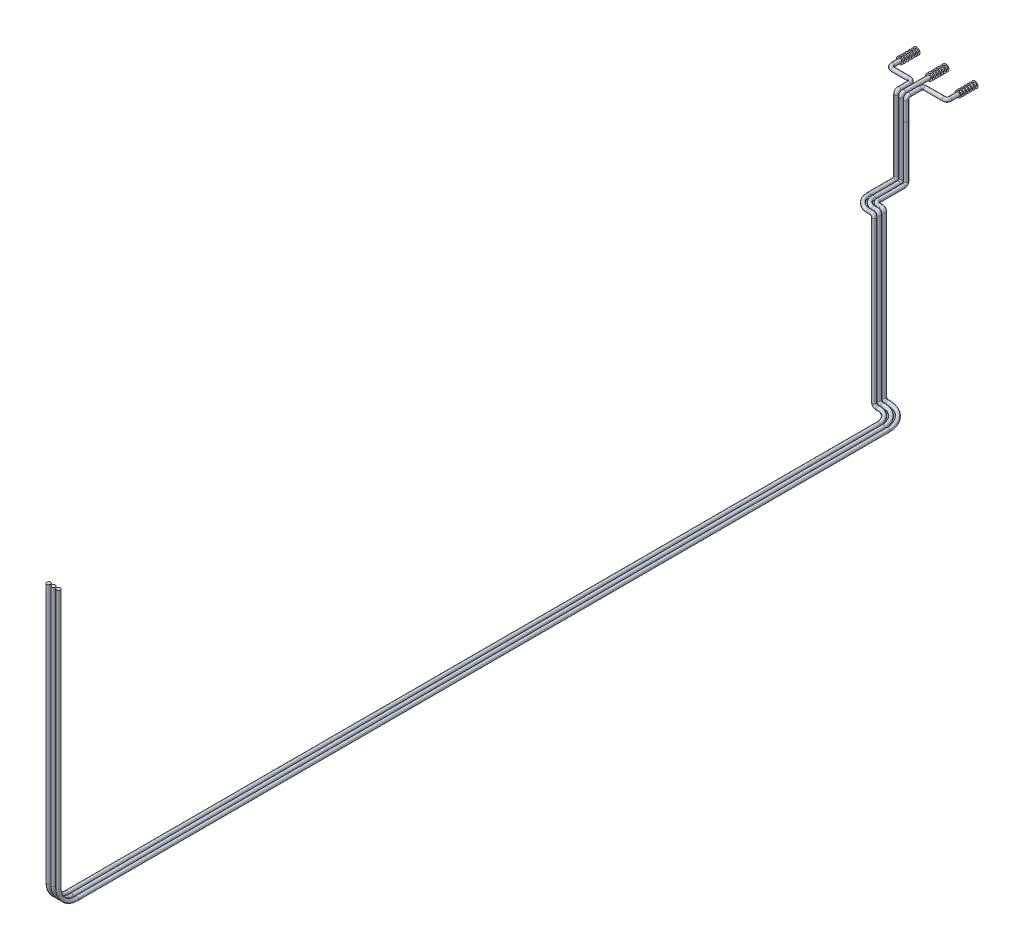
from build123d import *

# Parameters (mm, degrees)
BARRER5_PROFILE_R       = 13.7
BARRER6_PROFILE_R       = 13.7
CROQUIS41_R             = 13.7
CROQUIS62_R             = 22.870183784
CROQUIS62_R_2           = 24.36570856
CROQUIS62_R_3           = 24.738020287
SALIENTE_EXTRUIR1_DEPTH = 1
MATRIZL1_COUNT          = 7
MATRIZL1_PITCH          = 20
CROQUIS64_W             = 239.066100256
CROQUIS64_H             = 33.201144274
CORTAR_EXTRUIR1_DEPTH   = 5
CROQUIS65_R             = 13.7
CROQUIS65_R_2           = 13.697033


with BuildPart() as part:
    # Barrer5: sweep along a curve in space
    with BuildLine() as barrer5_path:
        Line((0, 0, 0), (0, 0, 170))
        ThreePointArc((0, 0, 170), (8.786796564, 0, 191.213203436), (30, 0, 200))
        Line((30, 0, 200), (145.00018, 0, 200))
        ThreePointArc((145.00018, 0, 200), (166.213383436, 0, 208.786796564), (175.00018, 0, 230))
        Line((175.00018, 0, 230), (175.00018, 0, 300))
        ThreePointArc((175.00018, 0, 300), (175.00018, -5.857864376, 314.142135624), (175.00018, -20, 320))
        Line((175.00018, -20, 320), (175.00018, -156.800061359, 320))
    # Barrer5 profile (on start of the path) → Barrer5 (sweep)
    with BuildSketch(Plane.XY):
        Circle(BARRER5_PROFILE_R)
    sweep(path=barrer5_path.line)


with BuildPart() as body_2:
    # Barrer6: sweep along a curve in space
    with BuildLine() as barrer6_path:
        Line((210, 0, 0), (210, 0, 299.997033))
        ThreePointArc((210, 0, 299.997033), (210, -5.857864376, 314.139168624), (210, -20, 319.997033))
        Line((210, -20, 319.997033), (210, -153.425324093, 319.997033))
    # Barrer6 profile (on start of the path) → Barrer6 (sweep)
    with BuildSketch(Plane(origin=(210, 0, 0), x_dir=(1, 0, 0), z_dir=(0, 0, 1))):
        Circle(BARRER6_PROFILE_R)
    sweep(path=barrer6_path.line)


with BuildPart() as body_3:
    # Barrer7: sweep along a curve in space
    with BuildLine() as barrer7_path:
        Line((420, 0, 0), (420, 0, 180))
        ThreePointArc((420, 0, 180), (414.142135624, 0, 194.142135624), (400, 0, 200))
        Line((400, 0, 200), (264.998005, 0, 200))
        ThreePointArc((264.998005, 0, 200), (250.855869376, 0, 205.857864376), (244.998005, 0, 220))
        Line((244.998005, 0, 220), (244.998005, 0, 300))
        ThreePointArc((244.998005, 0, 300), (244.998005, -5.857864376, 314.142135624), (244.998005, -20, 320))
        Line((244.998005, -20, 320), (244.998005, -158.814937218, 320))
    # Croquis41 → Barrer7 (sweep)
    with BuildSketch(Plane(origin=(0, 0, 0), x_dir=(-1, 0, 0), z_dir=(0, 0, -1))):
        with Locations((-420, 0)):
            Circle(CROQUIS41_R)
    sweep(path=barrer7_path.line)

    # Croquis62 → Saliente-Extruir1 (add)
    with BuildSketch(Plane(origin=(0, 0, 0), x_dir=(-1, 0, 0), z_dir=(0, 0, -1))):
        with Locations((-420, 0)):
            Circle(CROQUIS62_R)
        with Locations((-210, 0)):
            Circle(CROQUIS62_R_2)
        Circle(CROQUIS62_R_3)
    saliente_extruir1 = extrude(amount=SALIENTE_EXTRUIR1_DEPTH)


with BuildPart() as saliente_extruir1_piece_1:
    # of the separate pieces the step leaves, piece 1, a body of its own (saliente_extruir1_pieces)
    add(body_3.part.solids().sort_by_distance((397.129816216, 0, 0))[0])


with BuildPart() as saliente_extruir1_piece_2:
    # of the separate pieces the step leaves, piece 2, a body of its own (saliente_extruir1_pieces)
    add(body_3.part.solids().sort_by_distance((-24.738020287, 0, 0))[0])


with BuildPart() as saliente_extruir1_piece_3:
    # of the separate pieces the step leaves, piece 3, a body of its own (saliente_extruir1_pieces)
    add(body_3.part.solids().sort_by_distance((185.63429144, 0, 0))[0])


with BuildPart() as part_1:
    add(part.part)

    add(body_2.part)  # MatrizL1 merges body 2

    add(saliente_extruir1_piece_1.part)  # MatrizL1 merges Saliente-Extruir1 piece 1
    # MatrizL1: Saliente-Extruir1 ×7
    with Locations(*[(0, 0, i * MATRIZL1_PITCH) for i in range(1, MATRIZL1_COUNT)]):
        add(saliente_extruir1)

    # Croquis64 → Cortar-Extruir1 (cut)
    with BuildSketch(Plane.XZ.offset(158.814937218)):
        with Locations((191.41286696, 320.193015877)):
            Rectangle(CROQUIS64_W, CROQUIS64_H)
    extrude(amount=-CORTAR_EXTRUIR1_DEPTH, mode=Mode.SUBTRACT)

    # Barrer10: sweep along a curve in space
    with BuildLine() as barrer10_path:
        Line((175.00018, -153.425324093, 320), (175.00018, -531.355324093, 320))
        ThreePointArc((175.00018, -531.355324093, 320), (175.00018, -545.497459717, 325.857864376), (175.00018, -551.355324093, 340))
        Line((175.00018, -551.355324093, 340), (175.00018, -551.355324093, 520))
        ThreePointArc((175.00018, -551.355324093, 520), (204.289501881, -551.355324093, 590.710678119), (275.00018, -551.355324093, 620))
        Line((275.00018, -551.355324093, 620), (295.00018, -551.355324093, 620))
        ThreePointArc((295.00018, -551.355324093, 620), (309.142315624, -557.213188469, 620), (315.00018, -571.355324093, 620))
        Line((315.00018, -571.355324093, 620), (315.00018, -1730.355324093, 620))
        ThreePointArc((315.00018, -1730.355324093, 620), (320.858044376, -1744.497459717, 620), (335.00018, -1750.355324093, 620))
        Line((335.00018, -1750.355324093, 620), (344.639841001, -1750.355324093, 620))
        ThreePointArc((344.639841001, -1750.355324093, 620), (415.35051912, -1750.355324093, 649.289321881), (444.639841001, -1750.355324093, 720))
        Line((444.639841001, -1750.355324093, 720), (444.639841001, -1750.355324093, 6577.71847655))
        ThreePointArc((444.639841001, -1750.355324093, 6577.71847655), (444.639841001, -1712.279205647, 6669.642358104), (444.639841001, -1620.355324093, 6707.71847655))
        Line((444.639841001, -1620.355324093, 6707.71847655), (444.639841001, 249.644675907, 6707.71847655))
    # Croquis65 → Barrer10 (sweep)
    with BuildSketch(Plane.XZ.offset(153.425324093)):
        with Locations((175.00018, 320)):
            Circle(CROQUIS65_R)
        with Locations((210, 319.997033)):
            Circle(CROQUIS65_R)
        with Locations((244.998005, 320)):
            Circle(CROQUIS65_R_2)
    sweep(path=barrer10_path.line)


solid = Compound([saliente_extruir1_piece_2.part, saliente_extruir1_piece_3.part, part_1.part])
